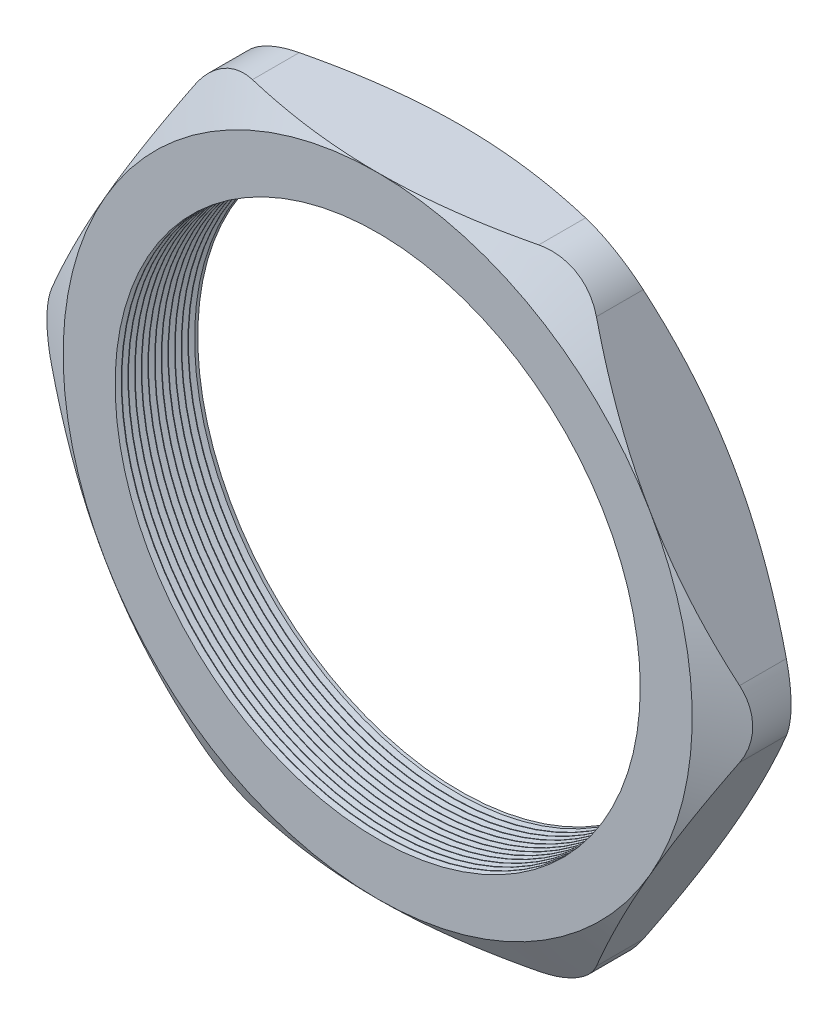
from build123d import *

# Parameters (mm, degrees)
SKETCH1_R          = 25.019
EXTRUDE1_DEPTH     = 7.874
SKETCH2_OUTSIDE_W  = 120.34
SKETCH2_OUTSIDE_H  = 111.066
SKETCH2_OUTSIDE_R  = 29.972
CUT_EXTRUDE1_DEPTH = 8.874
CUT_EXTRUDE1_DRAFT = -60
SKETCH3_OUTSIDE_W  = 120.34
SKETCH3_OUTSIDE_H  = 111.066
SKETCH3_OUTSIDE_R  = 29.972
CUT_EXTRUDE2_DEPTH = 8.874
CUT_EXTRUDE2_DRAFT = -60
FILLET1_R          = 6.35
LPATTERN1_COUNT    = 12
LPATTERN1_PITCH    = 0.635


with BuildPart() as part:
    # Sketch1 → Extrude1 (new body)
    with BuildSketch(Plane.XY):
        Polygon((-34.608684536, 0), (-17.304342268, -29.972), (17.304342268, -29.972), (34.608684536, 0), (17.304342268, 29.972), (-17.304342268, 29.972), align=None)
        Circle(SKETCH1_R, mode=Mode.SUBTRACT)
    extrude(amount=EXTRUDE1_DEPTH)


with BuildPart() as cut_extrude1_tool:
    # Sketch2 outside → Cut-Extrude1 (with draft: the straight prism first)
    with BuildSketch(Plane.XY.offset(7.874)):
        Rectangle(SKETCH2_OUTSIDE_W, SKETCH2_OUTSIDE_H)
        Circle(SKETCH2_OUTSIDE_R, mode=Mode.SUBTRACT)
    extrude(amount=-CUT_EXTRUDE1_DEPTH)
    # Cut-Extrude1: the draft: its side faces are tilted about the plane it starts from
    cut_extrude1_sides = [cut_extrude1_tool.faces().sort_by_distance(p)[0] for p in [
        (0, -55.533, 3.437),
        (60.17, 0, 3.437),
        (0, 55.533, 3.437),
        (-60.17, 0, 3.437),
        (-29.972, 0, 3.437),
    ]]
    draft(cut_extrude1_sides, Plane.XY.offset(7.874), CUT_EXTRUDE1_DRAFT)


with BuildPart() as part_1:
    add(part.part)

    # Cut-Extrude1: cut by cut_extrude1_tool
    add(cut_extrude1_tool.part, mode=Mode.SUBTRACT)


with BuildPart() as cut_extrude2_tool:
    # Sketch3 outside → Cut-Extrude2 (with draft: the straight prism first)
    with BuildSketch(Plane(origin=(0, 0, 0), x_dir=(-1, 0, 0), z_dir=(0, 0, -1))):
        Rectangle(SKETCH3_OUTSIDE_W, SKETCH3_OUTSIDE_H)
        Circle(SKETCH3_OUTSIDE_R, mode=Mode.SUBTRACT)
    extrude(amount=-CUT_EXTRUDE2_DEPTH)
    # Cut-Extrude2: the draft: its side faces are tilted about the plane it starts from
    cut_extrude2_sides = [cut_extrude2_tool.faces().sort_by_distance(p)[0] for p in [
        (0, -55.533, 4.437),
        (-60.17, 0, 4.437),
        (0, 55.533, 4.437),
        (60.17, 0, 4.437),
        (29.972, 0, 4.437),
    ]]
    draft(cut_extrude2_sides, Plane(origin=(0, 0, 0), x_dir=(-1, 0, 0), z_dir=(0, 0, -1)), CUT_EXTRUDE2_DRAFT)


with BuildPart() as part_2:
    add(part_1.part)

    # Cut-Extrude2: cut by cut_extrude2_tool
    add(cut_extrude2_tool.part, mode=Mode.SUBTRACT)

    # Fillet1
    fillet1_edges = [part_2.edges().sort_by_distance(p)[0] for p in [
        (34.608684536, 0, 3.937),
        (17.304342268, -29.972, 3.937),
        (-17.304342268, -29.972, 3.937),
        (-34.608684536, 0, 3.937),
        (-17.304342268, 29.972, 3.937),
        (17.304342268, 29.972, 3.937),
    ]]
    fillet(fillet1_edges, radius=FILLET1_R)

    # Sketch4 → Cut-Revolve1 (revolve, cut)
    with BuildSketch(Plane(origin=(0, 0, 0), x_dir=(1, 0, 0), z_dir=(0, 1, 0)), mode=Mode.PRIVATE) as cut_revolve1_sk:
        Polygon((-25.019, -7.874), (-25.019, -7.287412127), (-25.527, -7.580706063), align=None)
    cut_revolve1 = revolve(cut_revolve1_sk.sketch.rotate(Axis((0, 0, 0), (0, 0, 1)), 180), axis=Axis((0, 0, 0), (0, 0, 1)), mode=Mode.SUBTRACT)  # turned: the seam where the file's is

    # LPattern1: Cut-Revolve1 ×12
    with Locations(*[(0, 0, -i * LPATTERN1_PITCH) for i in range(1, LPATTERN1_COUNT)]):
        add(cut_revolve1, mode=Mode.SUBTRACT)


solid = part_2.part
